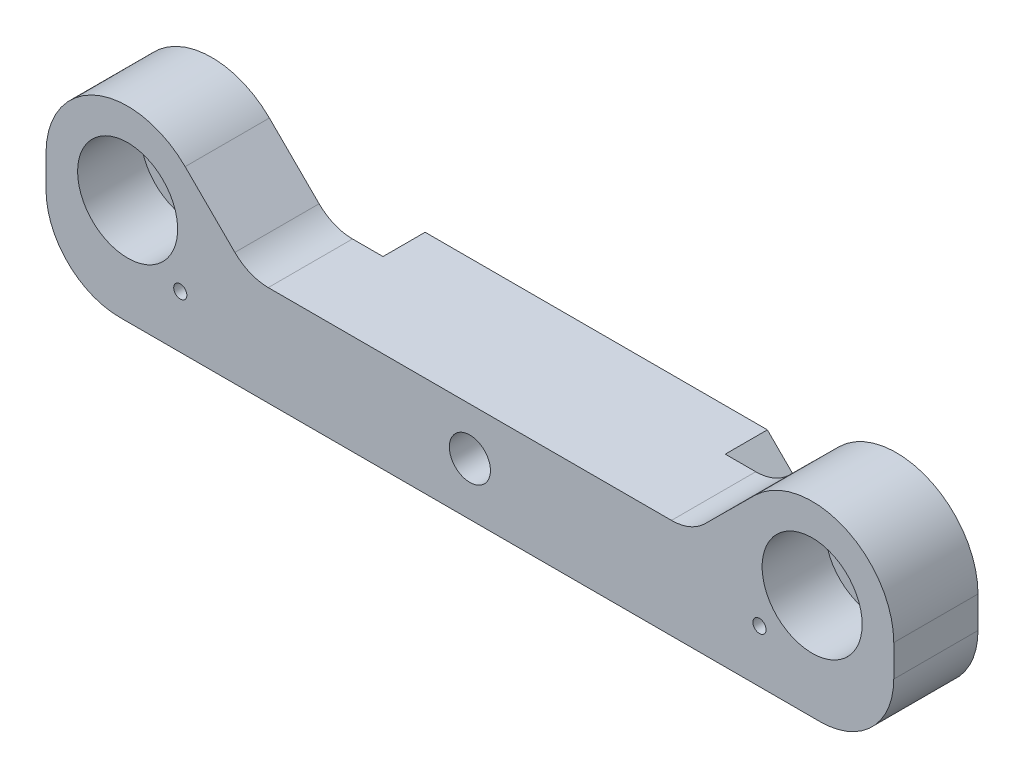
from build123d import *

# Parameters (mm, degrees)
SKETCH1_W                     = 78.5
SKETCH1_H                     = 7
BOSS_EXTRUDE1_DEPTH           = 12
BOSS_EXTRUDE1_DEPTH_BACK      = 12
SKETCH2_W                     = 20.5
SKETCH2_H                     = 6.3
CUT_EXTRUDE1_DEPTH            = 8
SKETCH3_W                     = 13.5
SKETCH3_H                     = 8.85
BOSS_EXTRUDE2_DEPTH           = 8
SKETCH4_R                     = 3.1
CUT_EXTRUDE2_DEPTH            = 22
CUT_EXTRUDE2_DEPTH_BACK       = 24.5
CUT_EXTRUDE3_DEPTH            = 5
SKETCH6_R                     = 6.2
CUT_EXTRUDE4_DEPTH            = 1
MIRROR2_COPY_1_SKETCH_R       = 6.2
MIRROR2_COPY_1_DEPTH          = 1
SKETCH7_W                     = 13.5
SKETCH7_H                     = 8.5
CUT_EXTRUDE5_DEPTH            = 1
MIRROR5_COPY_1_SKETCH_W       = 13.5
MIRROR5_COPY_1_SKETCH_H       = 8.5
MIRROR5_COPY_1_DEPTH          = 1
TAP_DRILL_FOR_M2_TAP1_D       = 1.6
CUT_EXTRUDE6_DEPTH            = 27
SKETCH12_W                    = 91.032241704
SKETCH12_H                    = 44.33734078
CUT_EXTRUDE7_DEPTH            = 22
F_2_0_2_DIAMETER_HOLE2_D      = 2
F_2_0_2_DIAMETER_HOLE2_DEPTH  = 16
F_2_0_2_DIAMETER_HOLE2_TIP    = 0.600860619
F_2_0_2_DIAMETER_HOLE1_D      = 2
F_2_0_2_DIAMETER_HOLE1_DEPTH  = 16
F_2_0_2_DIAMETER_HOLE1_TIP    = 0.600860619
ESQUISSE5_R                   = 3.1
BOSS_EXTRU_1_DEPTH            = 1
ESQUISSE6_R                   = 4.75
ENL_V_MAT_EXTRU_1_DEPTH       = 6
ESQUISSE7_R                   = 0.8
BOSS_EXTRU_2_DEPTH            = 8.85
BOSS_EXTRUDE3_DEPTH           = 1.5
SKETCH24_W                    = 22.483380367
SKETCH24_H                    = 20.071516443
CUT_EXTRUDE8_DEPTH            = 0.85
BOSS_EXTRUDE4_DEPTH           = 8
M2_5_CLEARANCE_HOLE1_D        = 2.9
M2_5_CLEARANCE_HOLE1_DEPTH    = 24
M2_5_CLEARANCE_HOLE1_TIP      = 0.871247898
SKETCH26_W                    = 37.5
SKETCH26_H                    = 12
BOSS_EXTRUDE6_DEPTH           = 1
SKETCH27_R                    = 1.95
CUT_EXTRUDE9_DEPTH            = 4.5
CHAMFER2_SIZE                 = 2.5
CUT_EXTRUDE10_DEPTH           = 10
ESQUISSE9_R                   = 0.6
ENL_V_MAT_EXTRU_2_DEPTH       = 13
SKETCH33_R                    = 7.75
SKETCH33_R_2                  = 4.75
BOSS_EXTRUDE9_DEPTH           = 8
SKETCH35_R                    = 1
BOSS_EXTRUDE10_DEPTH          = 2
BOSS_EXTRUDE11_DEPTH          = 8
FILLET2_R                     = 4.5
TAP_DRILL_FOR_M1_6_TAP1_D     = 1.25
TAP_DRILL_FOR_M1_6_TAP1_DEPTH = 24
TAP_DRILL_FOR_M1_6_TAP1_TIP   = 0.375537887
SKETCH40_W                    = 1
SKETCH40_H                    = 10
BOSS_EXTRUDE12_DEPTH          = 8
FILLET3_R                     = 7
SKETCH41_R                    = 0.582442918
BOSS_EXTRUDE13_DEPTH          = 8


with BuildPart() as part:
    # Sketch1 → Boss-Extrude1 (new body, two sides)
    with BuildSketch(Plane.XY) as boss_extrude1_sk:
        Rectangle(SKETCH1_W, SKETCH1_H)
    extrude(amount=BOSS_EXTRUDE1_DEPTH)
    extrude(boss_extrude1_sk.sketch, amount=-BOSS_EXTRUDE1_DEPTH_BACK)

    # Sketch2 → Cut-Extrude1 (cut, through all)
    with BuildSketch(Plane(origin=(0, 3.5, 0), x_dir=(1, 0, 0), z_dir=(0, 1, 0))):
        with Locations((-29, 0)):
            Rectangle(SKETCH2_W, SKETCH2_H)
        with Locations((29, 0)):
            Rectangle(SKETCH2_W, SKETCH2_H)
    extrude(amount=-CUT_EXTRUDE1_DEPTH, mode=Mode.SUBTRACT)

    # Sketch3 → Boss-Extrude2 (add)
    with BuildSketch(Plane(origin=(0, 3.5, 0), x_dir=(1, 0, 0), z_dir=(0, 1, 0))):
        with Locations((-32.5, 7.575)):
            Rectangle(SKETCH3_W, SKETCH3_H)
        with Locations((-32.5, -7.575)):
            Rectangle(SKETCH3_W, SKETCH3_H)
        with Locations((32.5, -7.575)):
            Rectangle(SKETCH3_W, SKETCH3_H)
        with Locations((32.5, 7.575)):
            Rectangle(SKETCH3_W, SKETCH3_H)
    extrude(amount=BOSS_EXTRUDE2_DEPTH)

    # Sketch4 → Cut-Extrude2 (cut, two sides)
    with BuildSketch(Plane.XY) as cut_extrude2_sk:
        with Locations((-32.5, 5)):
            Circle(SKETCH4_R)
        with Locations((32.5, 5)):
            Circle(SKETCH4_R)
    extrude(amount=CUT_EXTRUDE2_DEPTH, mode=Mode.SUBTRACT)
    extrude(cut_extrude2_sk.sketch, amount=-CUT_EXTRUDE2_DEPTH_BACK, mode=Mode.SUBTRACT)

    # Sketch5 → Cut-Extrude3 (cut)
    with BuildSketch(Plane.XY):
        Polygon((15, 3.5), (36.256888292, -2.195766051), (36.256888292, 11.5), (15, 11.5), align=None)
    extrude(amount=-CUT_EXTRUDE3_DEPTH, mode=Mode.SUBTRACT)

    # Sketch6 → Cut-Extrude4 (cut)
    with BuildSketch(Plane.XY.offset(12)):
        with Locations((32.5, 5)):
            Circle(SKETCH6_R)
    cut_extrude4 = extrude(amount=-CUT_EXTRUDE4_DEPTH, mode=Mode.SUBTRACT)

    # Mirror1: Cut-Extrude4 across plane
    add(cut_extrude4.mirror(Plane.XY), mode=Mode.SUBTRACT)

    # Mirror2: Cut-Extrude4 across plane
    add(cut_extrude4.mirror(Plane(origin=(0, 0, 0), x_dir=(0, 0, 1), z_dir=(1, 0, 0))), mode=Mode.SUBTRACT)

    # Mirror2 copy 1 sketch → Mirror2 copy 1 (cut)
    with BuildSketch(Plane(origin=(0, 0, -12), x_dir=(-1, 0, 0), z_dir=(0, 0, -1))):
        with Locations((32.5, 5)):
            Circle(MIRROR2_COPY_1_SKETCH_R)
    extrude(amount=-MIRROR2_COPY_1_DEPTH, mode=Mode.SUBTRACT)

    # Sketch7 → Cut-Extrude5 (cut)
    with BuildSketch(Plane.XY.offset(12)):
        with Locations((-32.5, 7.25)):
            Rectangle(SKETCH7_W, SKETCH7_H)
    cut_extrude5 = extrude(amount=-CUT_EXTRUDE5_DEPTH, mode=Mode.SUBTRACT)

    # Mirror3: Cut-Extrude5 across plane
    add(cut_extrude5.mirror(Plane(origin=(0, 0, 0), x_dir=(0, 0, 1), z_dir=(1, 0, 0))), mode=Mode.SUBTRACT)

    # Mirror5: Cut-Extrude5 across plane
    add(cut_extrude5.mirror(Plane.XY), mode=Mode.SUBTRACT)

    # Mirror5 copy 1 sketch → Mirror5 copy 1 (cut)
    with BuildSketch(Plane(origin=(0, 0, -12), x_dir=(-1, 0, 0), z_dir=(0, 0, -1))):
        with Locations((-32.5, 7.25)):
            Rectangle(MIRROR5_COPY_1_SKETCH_W, MIRROR5_COPY_1_SKETCH_H)
    extrude(amount=-MIRROR5_COPY_1_DEPTH, mode=Mode.SUBTRACT)

    # Tap Drill for M2 Tap1 (through all)
    with Locations(Plane.XY.offset(12)):
        with Locations((-25, 0), (0, 0), (25, 0)):
            Hole(TAP_DRILL_FOR_M2_TAP1_D / 2)

    # Sketch11 → Cut-Extrude6 (cut)
    with BuildSketch(Plane.XY.offset(12)):
        with BuildLine():
            Line((-39.25, 5), (-39.25, 21.221242017))
            Line((-39.25, 21.221242017), (-25.75, 21.221242017))
            Line((-25.75, 21.221242017), (-25.75, 5))
            ThreePointArc((-25.75, 5), (-32.5, 11.75), (-39.25, 5))
        make_face()
    extrude(amount=-CUT_EXTRUDE6_DEPTH, mode=Mode.SUBTRACT)

    # Sketch12 → Cut-Extrude7 (cut)
    with BuildSketch(Plane.XY):
        Rectangle(SKETCH12_W, SKETCH12_H)
    extrude(amount=-CUT_EXTRUDE7_DEPTH, mode=Mode.SUBTRACT)

    # 2.0 _2_ Diameter Hole2
    with Locations(Plane.XY.offset(12)):
        with Locations((-15, 0)):
            Hole(F_2_0_2_DIAMETER_HOLE2_D / 2, depth=F_2_0_2_DIAMETER_HOLE2_DEPTH)
            with Locations((0, 0, -(F_2_0_2_DIAMETER_HOLE2_DEPTH + F_2_0_2_DIAMETER_HOLE2_TIP / 2))):  # 118° drill point
                Cone(0, F_2_0_2_DIAMETER_HOLE2_D / 2, F_2_0_2_DIAMETER_HOLE2_TIP, mode=Mode.SUBTRACT)

    # 2.0 _2_ Diameter Hole1
    with Locations(Plane.XY.offset(12)):
        with Locations((15, 0)):
            Hole(F_2_0_2_DIAMETER_HOLE1_D / 2, depth=F_2_0_2_DIAMETER_HOLE1_DEPTH)
            with Locations((0, 0, -(F_2_0_2_DIAMETER_HOLE1_DEPTH + F_2_0_2_DIAMETER_HOLE1_TIP / 2))):  # 118° drill point
                Cone(0, F_2_0_2_DIAMETER_HOLE1_D / 2, F_2_0_2_DIAMETER_HOLE1_TIP, mode=Mode.SUBTRACT)

    # Esquisse5 → Boss.-Extru.1 (add)
    with BuildSketch(Plane.XY.offset(11)):
        with BuildLine():
            Line((25.75, 3), (26.6314397, 3))
            ThreePointArc((26.6314397, 3), (32.5, -1.2), (38.3685603, 3))
            Line((38.3685603, 3), (39.25, 3))
            Line((39.25, 3), (39.25, 11.5))
            Line((39.25, 11.5), (25.75, 11.5))
            Line((25.75, 11.5), (25.75, 3))
        make_face()
        with Locations((32.5, 5)):
            Circle(ESQUISSE5_R, mode=Mode.SUBTRACT)
    boss_extru_1 = extrude(amount=BOSS_EXTRU_1_DEPTH)

    # Esquisse6 → Enl_v. mat.-Extru.1 (cut)
    with BuildSketch(Plane.XY.offset(12)):
        with Locations((32.5, 5)):
            Circle(ESQUISSE6_R)
    enl_v_mat_extru_1 = extrude(amount=-ENL_V_MAT_EXTRU_1_DEPTH, mode=Mode.SUBTRACT)

    # Sym_trie1: Boss.-Extru.1, Enl_v. mat.-Extru.1 across plane
    add(boss_extru_1.mirror(Plane(origin=(0, 0, 0), x_dir=(0, 0, 1), z_dir=(1, 0, 0))))
    add(enl_v_mat_extru_1.mirror(Plane(origin=(0, 0, 0), x_dir=(0, 0, 1), z_dir=(1, 0, 0))), mode=Mode.SUBTRACT)

    # Esquisse7 → Boss.-Extru.2 (add)
    with BuildSketch(Plane.XY.offset(12)):
        with Locations((-25, 0)):
            Circle(ESQUISSE7_R)
        with Locations((25, 0)):
            Circle(ESQUISSE7_R)
    extrude(amount=-BOSS_EXTRU_2_DEPTH)

    # Sketch18 → Boss-Extrude3 (add)
    with BuildSketch(Plane.XZ.offset(3.5)):
        Polygon((-18.75, 0), (18.75, 0), (18.75, 3.15), (39.25, 3.15), (39.25, 12), (-39.25, 12), (-39.25, 3.15), (-18.75, 3.15), align=None)
    extrude(amount=BOSS_EXTRUDE3_DEPTH)

    # Sketch24 → Cut-Extrude8 (cut)
    with BuildSketch(Plane(origin=(0, 0, 3.15), x_dir=(-1, 0, 0), z_dir=(0, 0, -1))):
        with Locations((-29.991690184, 5.035758222)):
            Rectangle(SKETCH24_W, SKETCH24_H)
        with Locations((29.991690184, 5.035758222)):
            Rectangle(SKETCH24_W, SKETCH24_H)
    extrude(amount=-CUT_EXTRUDE8_DEPTH, mode=Mode.SUBTRACT)

    # Sketch19 → Boss-Extrude4 (add)
    with BuildSketch(Plane(origin=(0, 0, 4), x_dir=(-1, 0, 0), z_dir=(0, 0, -1))):
        Polygon((27.894392089, 9.934660654), (21, 3.5), (25.75, 3.5), align=None)
        Polygon((-25.75, 3.5), (-21, 3.5), (-27.894392089, 9.934660654), align=None)
    extrude(amount=-BOSS_EXTRUDE4_DEPTH)

    # M2.5 Clearance Hole1
    with Locations(Plane.XY.offset(12)):
        with Locations((0, 0)):
            Hole(M2_5_CLEARANCE_HOLE1_D / 2, depth=M2_5_CLEARANCE_HOLE1_DEPTH)
            with Locations((0, 0, -(M2_5_CLEARANCE_HOLE1_DEPTH + M2_5_CLEARANCE_HOLE1_TIP / 2))):  # 118° drill point
                Cone(0, M2_5_CLEARANCE_HOLE1_D / 2, M2_5_CLEARANCE_HOLE1_TIP, mode=Mode.SUBTRACT)

    # Sketch26 → Boss-Extrude6 (add)
    with BuildSketch(Plane(origin=(0, 3.5, 0), x_dir=(1, 0, 0), z_dir=(0, 1, 0))):
        with Locations((0, -6)):
            Rectangle(SKETCH26_W, SKETCH26_H)
    extrude(amount=BOSS_EXTRUDE6_DEPTH)

    # Sketch27 → Cut-Extrude9 (cut)
    with BuildSketch(Plane.XY.offset(12)):
        Circle(SKETCH27_R)
    extrude(amount=-CUT_EXTRUDE9_DEPTH, mode=Mode.SUBTRACT)

    # Chamfer2
    chamfer2_edges = [part.edges().sort_by_distance(p)[0] for p in [
        (18.75, 4.5, 6),
        (-18.75, 4.5, 6),
        (-18.75, -5, 2),
        (18.75, -5, 2),
    ]]
    chamfer(chamfer2_edges, length=CHAMFER2_SIZE)

    # Sketch32 → Cut-Extrude10 (cut)
    with BuildSketch(Plane(origin=(0, 0, 4), x_dir=(-1, 0, 0), z_dir=(0, 0, -1))):
        Polygon((24.736961251, 6.987773428), (32.5, 11.5), (37.878089133, 9.079051027), (39.25, 5), (41.051218968, 5), (41.051218968, 13.570990907), (25.598047204, 20.527242354), align=None)
        Polygon((-25.75, 7.933260788), (-32.5, 11.5), (-39.25, 7.747740561), (-44.98837862, 11.787792939), (-32.95842996, 17.943701699), (-19.091373489, 11.787792939), align=None)
    extrude(amount=-CUT_EXTRUDE10_DEPTH, mode=Mode.SUBTRACT)

    # Esquisse9 → Enl_v. mat.-Extru.2 (cut, through all)
    with BuildSketch(Plane.XY.offset(12)):
        with Locations((27.5, 0)):
            Circle(ESQUISSE9_R)
        with Locations((-27.5, 0)):
            Circle(ESQUISSE9_R)
    extrude(amount=-ENL_V_MAT_EXTRU_2_DEPTH, mode=Mode.SUBTRACT)

    # Sketch33 → Boss-Extrude9 (add)
    with BuildSketch(Plane(origin=(0, 0, 4), x_dir=(-1, 0, 0), z_dir=(0, 0, -1))):
        with Locations((32.5, 5)):
            Circle(SKETCH33_R)
        with Locations((32.5, 5)):
            Circle(SKETCH33_R_2, mode=Mode.SUBTRACT)
        with Locations((-32.5, 5)):
            Circle(SKETCH33_R)
        with Locations((-32.5, 5)):
            Circle(SKETCH33_R_2, mode=Mode.SUBTRACT)
    extrude(amount=-BOSS_EXTRUDE9_DEPTH)

    # Sketch35 → Boss-Extrude10 (add)
    with BuildSketch(Plane.XY.offset(12)):
        with Locations((-15, 0)):
            Circle(SKETCH35_R)
        with Locations((15, 0)):
            Circle(SKETCH35_R)
    extrude(amount=-BOSS_EXTRUDE10_DEPTH)

    # Sketch36 → Boss-Extrude11 (add)
    with BuildSketch(Plane(origin=(0, 0, 4), x_dir=(-1, 0, 0), z_dir=(0, 0, -1))):
        Polygon((-16.25, 4.5), (-18.75, -2.5), (-27.038121047, 10.49821592), (-21, 4.5), align=None)
        Polygon((18.75, -2.5), (27.038121047, 10.49821592), (21, 4.5), (16.25, 4.5), align=None)
    extrude(amount=-BOSS_EXTRUDE11_DEPTH)

    # Fillet2
    fillet2_edges = [part.edges().sort_by_distance(p)[0] for p in [
        (21, 4.5, 8),
        (-21, 4.5, 8),
    ]]
    fillet(fillet2_edges, radius=FILLET2_R)

    # Tap Drill for M1.6 Tap1
    with Locations(Plane.XY.offset(12)):
        with Locations((-27.500000533, 0.004370021), (27.499997993, -0.00437002)):
            Hole(TAP_DRILL_FOR_M1_6_TAP1_D / 2, depth=TAP_DRILL_FOR_M1_6_TAP1_DEPTH)
            with Locations((0, 0, -(TAP_DRILL_FOR_M1_6_TAP1_DEPTH + TAP_DRILL_FOR_M1_6_TAP1_TIP / 2))):  # 118° drill point
                Cone(0, TAP_DRILL_FOR_M1_6_TAP1_D / 2, TAP_DRILL_FOR_M1_6_TAP1_TIP, mode=Mode.SUBTRACT)

    # Sketch40 → Boss-Extrude12 (add)
    with BuildSketch(Plane(origin=(0, 0, 4), x_dir=(-1, 0, 0), z_dir=(0, 0, -1))):
        with Locations((39.75, 0)):
            Rectangle(SKETCH40_W, SKETCH40_H)
        with Locations((-39.75, 0)):
            Rectangle(SKETCH40_W, SKETCH40_H)
    extrude(amount=-BOSS_EXTRUDE12_DEPTH)

    # Fillet3
    fillet3_edges = [part.edges().sort_by_distance(p)[0] for p in [
        (-40.25, -5, 8),
        (40.25, -5, 8),
    ]]
    fillet(fillet3_edges, radius=FILLET3_R)

    # Sketch41 → Boss-Extrude13 (add)
    with BuildSketch(Plane(origin=(0, 0, 4), x_dir=(-1, 0, 0), z_dir=(0, 0, -1))):
        with Locations((-25.110595356, 7.336492886)):
            Circle(SKETCH41_R)
        with Locations((25.110595356, 7.336492886)):
            Circle(SKETCH41_R)
    extrude(amount=-BOSS_EXTRUDE13_DEPTH)


solid = part.part
